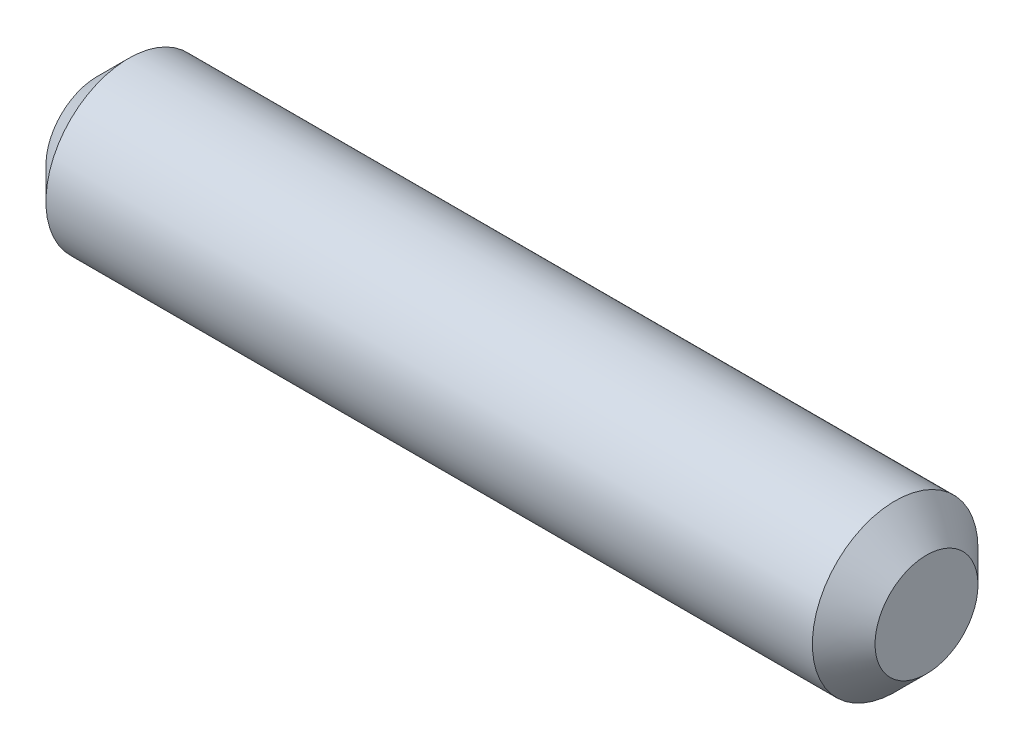
from build123d import *

# Parameters (mm, degrees)
SKETCH1_R           = 1.585
BOSS_EXTRUDE1_DEPTH = 7.935
CHAMFER1_SIZE       = 0.6


with BuildPart() as part:
    # Sketch1 → Boss-Extrude1 (new body, symmetric)
    with BuildSketch(Plane(origin=(0, 0, 0), x_dir=(0, 0, -1), z_dir=(1, 0, 0))):
        Circle(SKETCH1_R)
    extrude(amount=BOSS_EXTRUDE1_DEPTH, both=True)

    # Chamfer1
    chamfer1_edges = [part.edges().sort_by_distance(p)[0] for p in [
        (-7.935, 0, 1.585),
        (7.935, 0, 1.585),
    ]]
    chamfer(chamfer1_edges, length=CHAMFER1_SIZE)


solid = part.part
